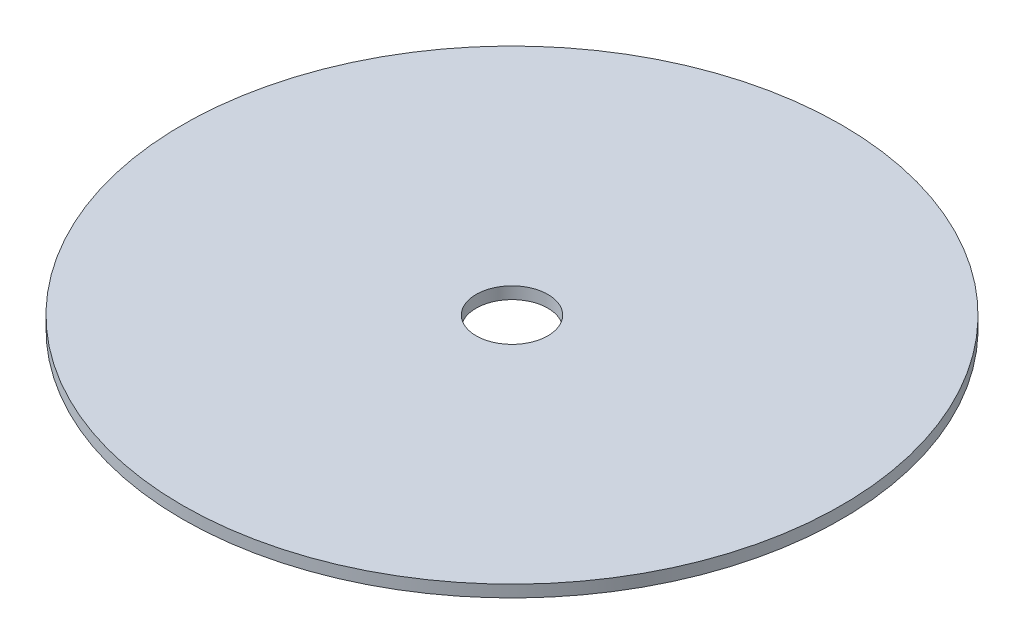
from build123d import *

# Parameters (mm, degrees)
SKETCH1_R           = 24.8
SKETCH1_R_2         = 2.7
BOSS_EXTRUDE1_DEPTH = 0.9
SKETCH2_R           = 21.2
SKETCH2_R_2         = 10.15
BOSS_EXTRUDE2_DEPTH = 2.25


with BuildPart() as part:
    # Sketch1 → Boss-Extrude1 (new body)
    with BuildSketch(Plane(origin=(0, 0, 0), x_dir=(1, 0, 0), z_dir=(0, 1, 0))):
        Circle(SKETCH1_R)
        Circle(SKETCH1_R_2, mode=Mode.SUBTRACT)
    extrude(amount=BOSS_EXTRUDE1_DEPTH)

    # Sketch2 → Boss-Extrude2 (add)
    with BuildSketch(Plane.XZ):
        Circle(SKETCH2_R)
        Circle(SKETCH2_R_2, mode=Mode.SUBTRACT)
    extrude(amount=BOSS_EXTRUDE2_DEPTH)


solid = part.part
